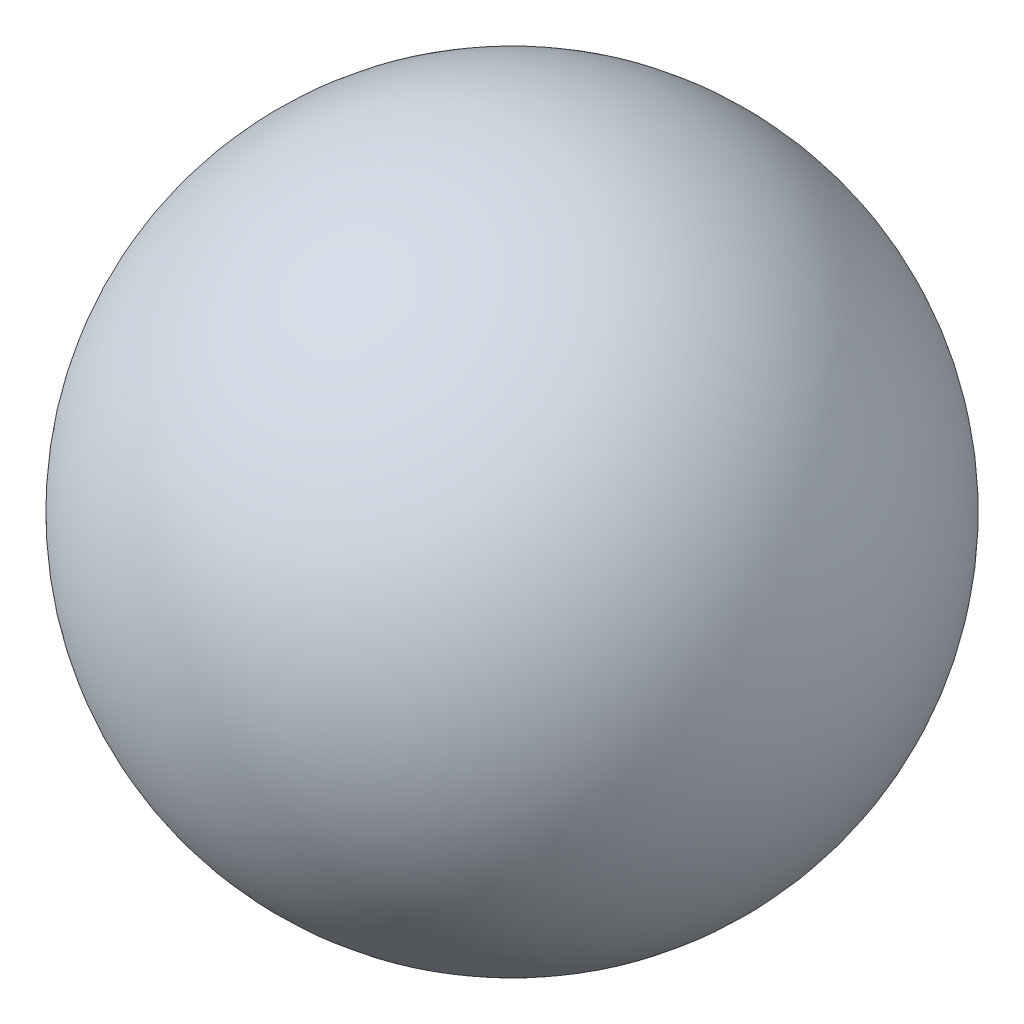
from build123d import *


with BuildPart() as part:
    # 草图1 → 旋转1 (revolve)
    with BuildSketch(Plane.XY):
        with BuildLine():
            Line((0, -1), (0, 1))
            ThreePointArc((0, 1), (1, 0), (0, -1))
        make_face()
    revolve(axis=Axis((0, 1, 0), (0, -1, 0)))


solid = part.part
